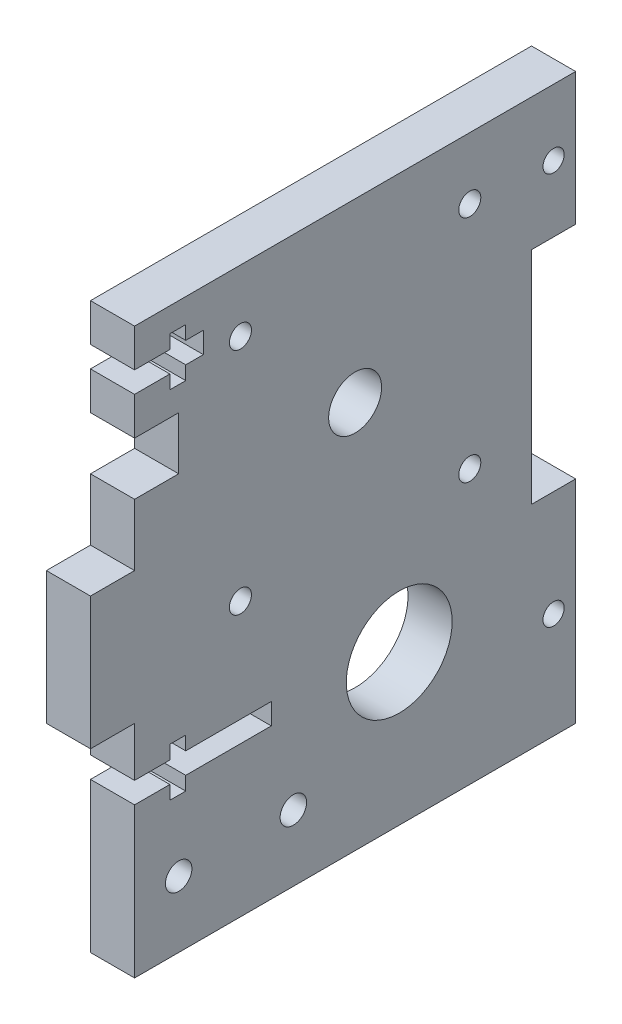
from build123d import *

# Parameters (mm, degrees)
SKETCH1_R           = 6
SKETCH1_R_2         = 3
SKETCH1_R_3         = 1.5
SKETCH1_R_4         = 1.25
SKETCH1_W           = 8
SKETCH1_H           = 2.4
BOSS_EXTRUDE1_DEPTH = 5
SKETCH2_R           = 1.2
CUT_EXTRUDE1_DEPTH  = 6


with BuildPart() as part:
    # Sketch1 → Boss-Extrude1 (new body)
    with BuildSketch(Plane(origin=(0, 0, 0), x_dir=(0, 0, -1), z_dir=(1, 0, 0))):
        Polygon((0, 0), (-50, 0), (-50, 25), (-55, 25), (-55, 40), (-50, 40), (-50, 47), (-45, 47), (-45, 53), (-50, 53), (-50, 64), (0, 64), (0, 49), (-5, 49), (-5, 24), (0, 24), align=None)
        with Locations((-20, 17)):
            Circle(SKETCH1_R, mode=Mode.SUBTRACT)
        with Locations((-25, 44)):
            Circle(SKETCH1_R_2, mode=Mode.SUBTRACT)
        with Locations((-45, 7.5)):
            Circle(SKETCH1_R_3, mode=Mode.SUBTRACT)
        with Locations((-38, 57)):
            Circle(SKETCH1_R_4, mode=Mode.SUBTRACT)
        with Locations((-12, 57)):
            Circle(SKETCH1_R_4, mode=Mode.SUBTRACT)
        with Locations((-38, 31)):
            Circle(SKETCH1_R_4, mode=Mode.SUBTRACT)
        with Locations((-12, 31)):
            Circle(SKETCH1_R_4, mode=Mode.SUBTRACT)
        with Locations((-32, 7.5)):
            Circle(SKETCH1_R_3, mode=Mode.SUBTRACT)
        with Locations((-38.5, 18.2)):
            Rectangle(SKETCH1_W, SKETCH1_H, mode=Mode.SUBTRACT)
    extrude(amount=BOSS_EXTRUDE1_DEPTH)

    # Sketch2 → Cut-Extrude1 (cut, through all)
    with BuildSketch(Plane.ZY):
        with Locations((2.5, 56.5)):
            Circle(SKETCH2_R)
        with Locations((2.5, 12)):
            Circle(SKETCH2_R)
        Polygon((50, 59.7), (46, 59.7), (46, 61.25), (44.2, 61.25), (44.2, 59.7), (42.2, 59.7), (42.2, 57.3), (44.2, 57.3), (44.2, 55.75), (46, 55.75), (46, 57.3), (50, 57.3), align=None)
        Polygon((50, 19.4), (46, 19.4), (46, 20.95), (44.2, 20.95), (44.2, 19.4), (42.2, 19.4), (42.2, 17), (44.2, 17), (44.2, 15.45), (46, 15.45), (46, 17), (50, 17), align=None)
    extrude(amount=-CUT_EXTRUDE1_DEPTH, mode=Mode.SUBTRACT)


solid = part.part
